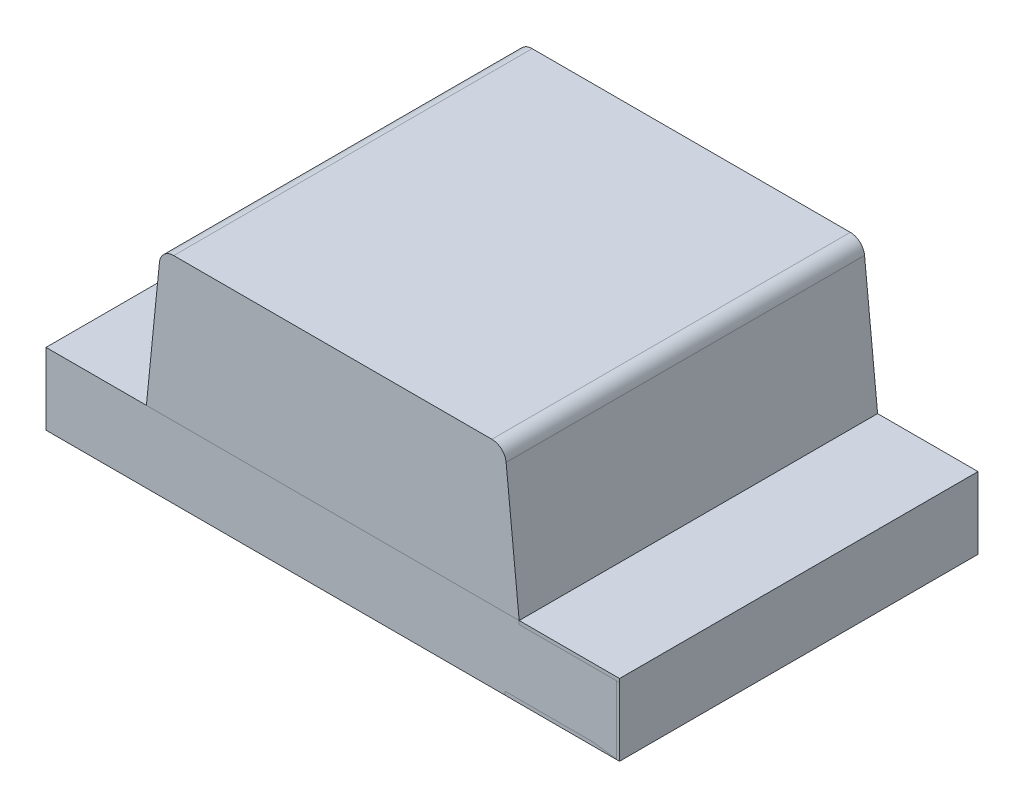
from build123d import *

# Parameters (mm, degrees)
SKETCH1_W             = 2
SKETCH1_H             = 0.25
EXTRUDE1_DEPTH        = 0.625
EXTRUDE2_DEPTH        = 0.625
EXTRUDE3_DEPTH        = 0.0001
EXTRUDE3_DEPTH_BACK   = 0.013
SKETCH2_3_W           = 0.4
SKETCH2_3_H           = 1.25
EXTRUDE4_DEPTH        = 0.0001
EXTRUDE4_DEPTH_BACK   = 0.012
EXTRUDE4_2_DEPTH      = 0.0001
EXTRUDE4_2_DEPTH_BACK = 0.012
SKETCH3_W             = 0.35
SKETCH3_H             = 1.25
EXTRUDE5_DEPTH        = 0.0001
EXTRUDE5_DEPTH_BACK   = 0.012
EXTRUDE5_2_DEPTH      = 0.0001
EXTRUDE5_2_DEPTH_BACK = 0.012
FILLET1_R             = 0.05
SKETCH5_W             = 1.25
SKETCH5_H             = 0.25
EXTRUDE6_DEPTH        = 0.0001
EXTRUDE6_DEPTH_BACK   = 0.01
SKETCH6_W             = 1.25
SKETCH6_H             = 0.2501
EXTRUDE7_DEPTH        = 0.0001
EXTRUDE7_DEPTH_BACK   = 0.01
SKETCH7_W             = 0.013291139
SKETCH7_H             = 0.012658228
CUT_EXTRUDE1_DEPTH    = 0.01


with BuildPart() as part:
    # Sketch1 → Extrude1 (new body, symmetric)
    with BuildSketch(Plane.XY):
        Rectangle(SKETCH1_W, SKETCH1_H)
    extrude(amount=EXTRUDE1_DEPTH, both=True)


with BuildPart() as body_2:
    # Sketch1_3 → Extrude2 (new body, symmetric)
    with BuildSketch(Plane.XY):
        Polygon((-0.6, 0.625), (-0.65, 0.125), (0.65, 0.125), (0.6, 0.625), align=None)
    extrude(amount=EXTRUDE2_DEPTH, both=True)

    # Fillet1
    fillet1_edges = [body_2.edges().sort_by_distance(p)[0] for p in [
        (0.6, 0.625, 0),
        (-0.6, 0.625, 0),
    ]]
    fillet(fillet1_edges, radius=FILLET1_R)


with BuildPart() as body_3:
    # Sketch2 → Extrude3 (new body, two sides)
    with BuildSketch(Plane.XZ.offset(0.125)) as extrude3_sk:
        Polygon((-0.339833711, 0.625), (-0.339833711, -0.625), (0.32532124, 0), align=None)
    extrude(amount=EXTRUDE3_DEPTH)
    extrude(extrude3_sk.sketch, amount=-EXTRUDE3_DEPTH_BACK)


with BuildPart() as body_4:
    # Sketch2_3 → Extrude4 (new body, two sides)
    with BuildSketch(Plane.XZ.offset(0.125)) as extrude4_sk:
        with Locations((-0.8, 0)):
            Rectangle(SKETCH2_3_W, SKETCH2_3_H)
    extrude(amount=EXTRUDE4_DEPTH)
    extrude(extrude4_sk.sketch, amount=-EXTRUDE4_DEPTH_BACK)


with BuildPart() as body_5:
    # Sketch2_3 → Extrude4 2 (new body, two sides)
    with BuildSketch(Plane.XZ.offset(0.125)) as extrude4_2_sk:
        with Locations((0.8, 0)):
            Rectangle(SKETCH2_3_W, SKETCH2_3_H)
    extrude(amount=EXTRUDE4_2_DEPTH)
    extrude(extrude4_2_sk.sketch, amount=-EXTRUDE4_2_DEPTH_BACK)


with BuildPart() as body_6:
    # Sketch3 → Extrude5 (new body, two sides)
    with BuildSketch(Plane(origin=(0, 0.125, 0), x_dir=(-1, 0, 0), z_dir=(0, 1, 0))) as extrude5_sk:
        with Locations((0.825, 0)):
            Rectangle(SKETCH3_W, SKETCH3_H)
    extrude(amount=EXTRUDE5_DEPTH)
    extrude(extrude5_sk.sketch, amount=-EXTRUDE5_DEPTH_BACK)


with BuildPart() as body_7:
    # Sketch3 → Extrude5 2 (new body, two sides)
    with BuildSketch(Plane(origin=(0, 0.125, 0), x_dir=(-1, 0, 0), z_dir=(0, 1, 0))) as extrude5_2_sk:
        with Locations((-0.825, 0)):
            Rectangle(SKETCH3_W, SKETCH3_H)
    extrude(amount=EXTRUDE5_2_DEPTH)
    extrude(extrude5_2_sk.sketch, amount=-EXTRUDE5_2_DEPTH_BACK)


with BuildPart() as body_8:
    # Sketch5 → Extrude6 (new body, two sides)
    with BuildSketch(Plane(origin=(1, 0, 0), x_dir=(0, 0, -1), z_dir=(1, 0, 0))) as extrude6_sk:
        Rectangle(SKETCH5_W, SKETCH5_H)
    extrude(amount=EXTRUDE6_DEPTH)
    extrude(extrude6_sk.sketch, amount=-EXTRUDE6_DEPTH_BACK)


with BuildPart() as body_9:
    # Sketch6 → Extrude7 (new body, two sides)
    with BuildSketch(Plane.ZY.offset(1)) as extrude7_sk:
        with Locations((0, -5e-05)):
            Rectangle(SKETCH6_W, SKETCH6_H)
    extrude(amount=EXTRUDE7_DEPTH)
    extrude(extrude7_sk.sketch, amount=-EXTRUDE7_DEPTH_BACK)


with BuildPart() as cut_extrude1_tool:
    # Sketch7 → Cut-Extrude1 (new body)
    with BuildSketch(Plane.XZ.offset(0.1251)):
        Polygon((-0.87901904, 0.291273719), (-0.916360812, 0.303002358), (-0.916360812, 0.315373798), (-0.891192695, 0.323581868), (-0.916360812, 0.331344922), (-0.916360812, 0.344210823), (-0.87901904, 0.355830681), (-0.87901904, 0.343241678), (-0.904760733, 0.336744447), (-0.87901904, 0.328536377), (-0.87901904, 0.317786773), (-0.904760733, 0.309628149), (-0.87901904, 0.303219922), align=None)
        Polygon((-0.87901904, 0.224185111), (-0.916360812, 0.235913751), (-0.916360812, 0.248285191), (-0.891192695, 0.25649326), (-0.916360812, 0.264256314), (-0.916360812, 0.277122216), (-0.87901904, 0.288742073), (-0.87901904, 0.27615307), (-0.904760733, 0.269655839), (-0.87901904, 0.26144777), (-0.87901904, 0.250698165), (-0.904760733, 0.242539542), (-0.87901904, 0.236131314), align=None)
        Polygon((-0.87901904, 0.157096504), (-0.916360812, 0.168825143), (-0.916360812, 0.181196583), (-0.891192695, 0.189404653), (-0.916360812, 0.197167706), (-0.916360812, 0.210033608), (-0.87901904, 0.221653466), (-0.87901904, 0.209064463), (-0.904760733, 0.202567232), (-0.87901904, 0.194359162), (-0.87901904, 0.183609558), (-0.904760733, 0.175450934), (-0.87901904, 0.169042706), align=None)
        with Locations((-0.909715243, 0.143172453)):
            Rectangle(SKETCH7_W, SKETCH7_H)
        with BuildLine():
            add(Edge.make_bspline(
                [(-0.900775369, 0.084944605), (-0.901386436, 0.084962854), (-0.902586367, 0.084998689), (-0.904340211, 0.085303483), (-0.906002363, 0.085800466), (-0.907584436, 0.086486636), (-0.90906918, 0.087383364), (-0.910470626, 0.088474999), (-0.911772898, 0.089769441), (-0.912991086, 0.091242843), (-0.914082141, 0.092891314), (-0.915035158, 0.094690171), (-0.915832493, 0.096630185), (-0.916502026, 0.09870429), (-0.916996243, 0.100927564), (-0.917358237, 0.103286313), (-0.917594895, 0.105783027), (-0.917615879, 0.107494815), (-0.917626635, 0.108372216)],
                knots=[0, 0, 0, 0, 0.907312236, 1.78165839, 2.635367075, 3.479697475, 4.336364812, 5.205276731, 6.11257575, 7.058770404, 8.040786331, 9.044147278, 10.078219212, 11.153049307, 12.278104542, 13.457648573, 14.696882856, 16, 16, 16, 16], degree=3))
            add(Edge.make_bspline(
                [(-0.917626635, 0.108372216), (-0.917614599, 0.109381344), (-0.917591287, 0.111335935), (-0.917376987, 0.114167697), (-0.917053918, 0.116801716), (-0.916570647, 0.119249573), (-0.915970264, 0.121551873), (-0.915324618, 0.123768507), (-0.914592411, 0.125909163), (-0.914042332, 0.127295707), (-0.913769831, 0.12798258)],
                knots=[0, 0, 0, 0, 1.203215828, 2.33052265, 3.384689099, 4.366106119, 5.303329643, 6.221311756, 7.118865988, 8, 8, 8, 8], degree=3))
            Line((-0.913769831, 0.12798258), (-0.90180385, 0.12798258))
            Line((-0.90180385, 0.12798258), (-0.90180385, 0.126558529))
            add(Edge.make_bspline(
                [(-0.90180385, 0.126558529), (-0.902344578, 0.125875872), (-0.903422858, 0.124514566), (-0.904804161, 0.122297949), (-0.906005242, 0.119974126), (-0.906992243, 0.117551391), (-0.907785405, 0.115102969), (-0.908332169, 0.11266528), (-0.908705843, 0.110282486), (-0.908746097, 0.108703201), (-0.908765876, 0.1079272)],
                knots=[0, 0, 0, 0, 1.030622468, 2.055194264, 3.087043286, 4.125157485, 5.149848264, 6.130935704, 7.081611712, 8, 8, 8, 8], degree=3))
            add(Edge.make_bspline(
                [(-0.908765876, 0.1079272), (-0.908765428, 0.107712811), (-0.908764471, 0.10725382), (-0.908700049, 0.106519801), (-0.908653468, 0.105690502), (-0.908548859, 0.104801069), (-0.908439567, 0.10390566), (-0.908249407, 0.10307833), (-0.908068488, 0.10232651), (-0.907884399, 0.101873269), (-0.90779673, 0.101657422)],
                knots=[0, 0, 0, 0, 0.806378557, 1.726393851, 2.771014456, 3.931269413, 5.096090628, 6.161710732, 7.124547685, 8, 8, 8, 8], degree=3))
            add(Edge.make_bspline(
                [(-0.90779673, 0.101657422), (-0.907682818, 0.101417528), (-0.907458957, 0.100946087), (-0.907050154, 0.100298627), (-0.906614503, 0.099707291), (-0.906131793, 0.09917656), (-0.905542839, 0.098751427), (-0.904842411, 0.098437326), (-0.904017261, 0.098265779), (-0.903429755, 0.098246132), (-0.903119119, 0.098235744)],
                knots=[0, 0, 0, 0, 1.024407818, 2.013179384, 2.949802342, 3.859052226, 4.77034807, 5.732977883, 6.801339628, 8, 8, 8, 8], degree=3))
            add(Edge.make_bspline(
                [(-0.903119119, 0.098235744), (-0.902846171, 0.098251465), (-0.902309475, 0.098282377), (-0.901545477, 0.098573273), (-0.900834538, 0.099014722), (-0.900204181, 0.099658233), (-0.899625462, 0.100455271), (-0.899140313, 0.10143314), (-0.898700276, 0.102559629), (-0.898491642, 0.103381859), (-0.898382173, 0.103813276)],
                knots=[0, 0, 0, 0, 0.825212765, 1.622611382, 2.449701629, 3.348069183, 4.336544339, 5.428209675, 6.6506027, 8, 8, 8, 8], degree=3))
            add(Edge.make_bspline(
                [(-0.898382173, 0.103813276), (-0.898158303, 0.10479764), (-0.897699708, 0.106814093), (-0.897126154, 0.109888148), (-0.896493118, 0.112953262), (-0.895888347, 0.114932618), (-0.895593407, 0.115897928)],
                knots=[0, 0, 0, 0, 0.976104583, 1.999535498, 3.024395274, 4, 4, 4, 4], degree=3))
            add(Edge.make_bspline(
                [(-0.895593407, 0.115897928), (-0.895416911, 0.116417186), (-0.895073344, 0.11742797), (-0.894492532, 0.118873742), (-0.893857556, 0.120204298), (-0.89317999, 0.121424353), (-0.892442991, 0.122524014), (-0.891676296, 0.123521609), (-0.890849378, 0.124393372), (-0.889983418, 0.125167214), (-0.889057417, 0.125828871), (-0.888085348, 0.126406247), (-0.887055116, 0.126894064), (-0.885974471, 0.127298506), (-0.884835037, 0.127607042), (-0.8836466, 0.12781767), (-0.88240492, 0.127966865), (-0.881557744, 0.12797727), (-0.881125448, 0.12798258)],
                knots=[0, 0, 0, 0, 1.287286806, 2.505824366, 3.654938963, 4.74627059, 5.778586806, 6.75996495, 7.696030012, 8.595059759, 9.482019644, 10.363222407, 11.245851011, 12.154256429, 13.068444161, 14.012503255, 14.985824751, 16, 16, 16, 16], degree=3))
            add(Edge.make_bspline(
                [(-0.881125448, 0.12798258), (-0.880547376, 0.127963929), (-0.87940974, 0.127927224), (-0.877745218, 0.12762651), (-0.876170849, 0.127113215), (-0.874669118, 0.126420183), (-0.873262575, 0.125505869), (-0.871923301, 0.124413472), (-0.870687505, 0.123101448), (-0.869537339, 0.121612887), (-0.868497639, 0.119969195), (-0.867582361, 0.118199703), (-0.866814035, 0.116315059), (-0.866177088, 0.114322285), (-0.865699753, 0.112213051), (-0.865340287, 0.109994435), (-0.865133696, 0.10765754), (-0.865108071, 0.106061829), (-0.865094989, 0.105247216)],
                knots=[0, 0, 0, 0, 0.894990994, 1.761326291, 2.609044902, 3.454222546, 4.315366365, 5.200560057, 6.125081389, 7.100429509, 8.110379559, 9.133447974, 10.182136699, 11.259192205, 12.370181258, 13.528580438, 14.738335141, 16, 16, 16, 16], degree=3))
            add(Edge.make_bspline(
                [(-0.865094989, 0.105247216), (-0.865106085, 0.104412872), (-0.865128258, 0.1027456), (-0.865317247, 0.100254879), (-0.865594861, 0.097774628), (-0.866015714, 0.095342713), (-0.866503922, 0.092997435), (-0.86705182, 0.090790817), (-0.867670802, 0.088751087), (-0.868147975, 0.087464255), (-0.868378217, 0.086843339)],
                knots=[0, 0, 0, 0, 1.065403572, 2.129000689, 3.188532477, 4.251604565, 5.279552602, 6.247508681, 7.154397237, 8, 8, 8, 8], degree=3))
            Line((-0.868378217, 0.086843339), (-0.879651951, 0.086843339))
            Line((-0.879651951, 0.086843339), (-0.879651951, 0.088257501))
            add(Edge.make_bspline(
                [(-0.879651951, 0.088257501), (-0.879251778, 0.088793953), (-0.878433413, 0.089891012), (-0.877391577, 0.091720831), (-0.876412644, 0.093699948), (-0.875570565, 0.095839364), (-0.874840824, 0.098068877), (-0.874331241, 0.100360357), (-0.874010336, 0.102673439), (-0.873973949, 0.104224294), (-0.873955749, 0.104999985)],
                knots=[0, 0, 0, 0, 0.892283326, 1.824742884, 2.804416662, 3.836872171, 4.8899239, 5.931447339, 6.965372909, 8, 8, 8, 8], degree=3))
            add(Edge.make_bspline(
                [(-0.873955749, 0.104999985), (-0.873966475, 0.105547819), (-0.873987926, 0.106643427), (-0.874183268, 0.108277531), (-0.874498715, 0.109898562), (-0.874908356, 0.110918823), (-0.87511279, 0.111427991)],
                knots=[0, 0, 0, 0, 0.999146175, 1.998183711, 3.000980573, 4, 4, 4, 4], degree=3))
            add(Edge.make_bspline(
                [(-0.87511279, 0.111427991), (-0.875213524, 0.111644743), (-0.875414923, 0.112078101), (-0.875801205, 0.112681424), (-0.876265611, 0.113233758), (-0.876791607, 0.113729797), (-0.877369793, 0.114163996), (-0.878007206, 0.114471671), (-0.878688664, 0.114659608), (-0.879156279, 0.114680687), (-0.879394831, 0.114691441)],
                knots=[0, 0, 0, 0, 1.00524851, 2.009826503, 3.004679593, 4.035271301, 5.048246368, 6.034938417, 6.997532266, 8, 8, 8, 8], degree=3))
            add(Edge.make_bspline(
                [(-0.879394831, 0.114691441), (-0.879713914, 0.114674221), (-0.880323652, 0.114641317), (-0.88118155, 0.114338025), (-0.881920767, 0.113845608), (-0.882418227, 0.113265306), (-0.882766946, 0.112706741), (-0.883022201, 0.112188912), (-0.88326388, 0.111584298), (-0.883512615, 0.110898674), (-0.883758208, 0.110130511), (-0.883995982, 0.109276232), (-0.88422063, 0.108334874), (-0.884363725, 0.107676936), (-0.884438344, 0.107333846)],
                knots=[0, 0, 0, 0, 1.173816843, 2.243057204, 3.312297565, 4.415174738, 5.03266065, 5.73970059, 6.541434878, 7.433956553, 8.430083051, 9.515931566, 10.70464786, 12, 12, 12, 12], degree=3))
            add(Edge.make_bspline(
                [(-0.884438344, 0.107333846), (-0.884626375, 0.106417451), (-0.884995814, 0.104616938), (-0.885547558, 0.101916346), (-0.886185042, 0.099164959), (-0.886759444, 0.097332296), (-0.887058993, 0.096376567)],
                knots=[0, 0, 0, 0, 0.995744513, 1.956417928, 2.934277412, 4, 4, 4, 4], degree=3))
            add(Edge.make_bspline(
                [(-0.887058993, 0.096376567), (-0.887218615, 0.09590329), (-0.887530861, 0.094977484), (-0.888074002, 0.093657168), (-0.888660994, 0.092433639), (-0.889281759, 0.091300122), (-0.889953742, 0.090263138), (-0.890665066, 0.089315796), (-0.89142852, 0.088473887), (-0.892235134, 0.087725104), (-0.893090184, 0.087065525), (-0.894009721, 0.086499375), (-0.894984122, 0.086013261), (-0.896027222, 0.085628459), (-0.897124515, 0.085319449), (-0.898290199, 0.0851079), (-0.899512387, 0.084960908), (-0.900349676, 0.0849501), (-0.900775369, 0.084944605)],
                knots=[0, 0, 0, 0, 1.237467875, 2.420686895, 3.535046182, 4.599015201, 5.620884487, 6.594603852, 7.531477383, 8.433220087, 9.318759595, 10.202828513, 11.105163009, 12.01247538, 12.953896178, 13.926381251, 14.945733412, 16, 16, 16, 16], degree=3))
        make_face()
        with BuildLine():
            Line((-0.916360812, 0.038742073), (-0.916360812, 0.05076739))
            Line((-0.916360812, 0.05076739), (-0.912444673, 0.05076739))
            add(Edge.make_bspline(
                [(-0.912444673, 0.05076739), (-0.912848952, 0.051314044), (-0.913628397, 0.052367986), (-0.914668505, 0.053954498), (-0.915556138, 0.055467544), (-0.916335749, 0.056924289), (-0.916923441, 0.058435391), (-0.917337474, 0.060051148), (-0.917587361, 0.06180256), (-0.917613253, 0.063016007), (-0.917626635, 0.063643181)],
                knots=[0, 0, 0, 0, 1.150872466, 2.218865267, 3.209461834, 4.120482262, 5.012764827, 5.946708227, 6.938749913, 8, 8, 8, 8], degree=3))
            add(Edge.make_bspline(
                [(-0.917626635, 0.063643181), (-0.917615276, 0.064151357), (-0.917593155, 0.065140922), (-0.917420716, 0.066579542), (-0.917151891, 0.067933356), (-0.916748095, 0.069190876), (-0.916265194, 0.070372871), (-0.915625215, 0.071441646), (-0.914910128, 0.072443446), (-0.914056605, 0.073334283), (-0.913107738, 0.074142093), (-0.912041508, 0.074833368), (-0.910875045, 0.075422224), (-0.909599118, 0.075892773), (-0.908219967, 0.076270318), (-0.906730343, 0.076532284), (-0.905136779, 0.07669258), (-0.904039214, 0.07670855), (-0.903475132, 0.076716757)],
                knots=[0, 0, 0, 0, 1.109008058, 2.159558935, 3.158726032, 4.116861086, 5.039058877, 5.938775559, 6.82970133, 7.720510853, 8.624361809, 9.544451588, 10.487360536, 11.471068125, 12.508000841, 13.604731202, 14.768976642, 16, 16, 16, 16], degree=3))
            Line((-0.903475132, 0.076716757), (-0.87901904, 0.076716757))
            Line((-0.87901904, 0.076716757), (-0.87901904, 0.064691441))
            Line((-0.87901904, 0.064691441), (-0.897808597, 0.064691441))
            add(Edge.make_bspline(
                [(-0.897808597, 0.064691441), (-0.898266833, 0.064690623), (-0.89914394, 0.064689057), (-0.900396844, 0.064647888), (-0.90153093, 0.064587438), (-0.902551944, 0.064518085), (-0.90347532, 0.064391577), (-0.9043084, 0.064202723), (-0.905068201, 0.06396731), (-0.905521552, 0.06373515), (-0.905739768, 0.063623403)],
                knots=[0, 0, 0, 0, 1.361401701, 2.605856924, 3.723918663, 4.735739235, 5.645738665, 6.489217889, 7.27279937, 8, 8, 8, 8], degree=3))
            add(Edge.make_bspline(
                [(-0.905739768, 0.063623403), (-0.905939125, 0.063508399), (-0.906331045, 0.063282312), (-0.906834134, 0.062822168), (-0.907256268, 0.062282796), (-0.907584282, 0.061643994), (-0.907833757, 0.06090072), (-0.908003875, 0.060036755), (-0.908111626, 0.059044074), (-0.90812558, 0.058339565), (-0.908132964, 0.057966757)],
                knots=[0, 0, 0, 0, 0.849138082, 1.669332372, 2.503455908, 3.370611167, 4.311442699, 5.394692208, 6.621337967, 8, 8, 8, 8], degree=3))
            add(Edge.make_bspline(
                [(-0.908132964, 0.057966757), (-0.908124286, 0.057696115), (-0.908106442, 0.057139656), (-0.907990219, 0.056284), (-0.907811882, 0.055385711), (-0.907481954, 0.05412842), (-0.906888864, 0.052545107), (-0.906211661, 0.051365456), (-0.905868328, 0.05076739)],
                knots=[0, 0, 0, 0, 0.638127216, 1.312033637, 2.033062677, 2.79661882, 4.375931797, 6, 6, 6, 6], degree=3))
            Line((-0.905868328, 0.05076739), (-0.87901904, 0.05076739))
            Line((-0.87901904, 0.05076739), (-0.87901904, 0.038742073))
            Line((-0.87901904, 0.038742073), (-0.916360812, 0.038742073))
        make_face()
        with BuildLine():
            Line((-0.916360812, -0.009992104), (-0.916360812, 0.002033213))
            Line((-0.916360812, 0.002033213), (-0.897571255, 0.002033213))
            add(Edge.make_bspline(
                [(-0.897571255, 0.002033213), (-0.896806234, 0.00204547), (-0.895280721, 0.002069912), (-0.893399516, 0.002210974), (-0.891978354, 0.002400235), (-0.891059413, 0.002585062), (-0.890285344, 0.002800912), (-0.889842464, 0.003007052), (-0.889640084, 0.003101251)],
                knots=[0, 0, 0, 0, 1.709124929, 3.408128882, 4.211124727, 4.91016634, 5.501986363, 6, 6, 6, 6], degree=3))
            add(Edge.make_bspline(
                [(-0.889640084, 0.003101251), (-0.889441058, 0.003223482), (-0.889050838, 0.003463134), (-0.888544331, 0.003931796), (-0.888129911, 0.004478739), (-0.887789136, 0.005114124), (-0.887553845, 0.005859722), (-0.88735723, 0.006718092), (-0.887273776, 0.007711401), (-0.887256196, 0.008415036), (-0.887246888, 0.008787564)],
                knots=[0, 0, 0, 0, 0.86006424, 1.686277094, 2.52783008, 3.38194165, 4.331801563, 5.402842185, 6.624978739, 8, 8, 8, 8], degree=3))
            add(Edge.make_bspline(
                [(-0.887246888, 0.008787564), (-0.887275257, 0.009353475), (-0.887333184, 0.010509022), (-0.887688937, 0.011940119), (-0.888098417, 0.013105421), (-0.888477832, 0.014031683), (-0.888963553, 0.014985998), (-0.889324464, 0.015625704), (-0.889511524, 0.015957263)],
                knots=[0, 0, 0, 0, 1.338371478, 2.732853438, 3.468019217, 4.261884641, 5.099136535, 6, 6, 6, 6], degree=3))
            Line((-0.889511524, 0.015957263), (-0.916360812, 0.015957263))
            Line((-0.916360812, 0.015957263), (-0.916360812, 0.02798258))
            Line((-0.916360812, 0.02798258), (-0.87901904, 0.02798258))
            Line((-0.87901904, 0.02798258), (-0.87901904, 0.015957263))
            Line((-0.87901904, 0.015957263), (-0.882935179, 0.015957263))
            add(Edge.make_bspline(
                [(-0.882935179, 0.015957263), (-0.882532104, 0.01542856), (-0.881747492, 0.014399408), (-0.880727282, 0.012809789), (-0.879827898, 0.01126784), (-0.879071489, 0.009741335), (-0.878468102, 0.008183858), (-0.878062607, 0.006552478), (-0.877790706, 0.004844275), (-0.877765859, 0.003675918), (-0.877753217, 0.003081472)],
                knots=[0, 0, 0, 0, 1.126119141, 2.192057864, 3.198061997, 4.149848529, 5.076251285, 6.021887753, 6.99356175, 8, 8, 8, 8], degree=3))
            add(Edge.make_bspline(
                [(-0.877753217, 0.003081472), (-0.877765912, 0.002583336), (-0.877790694, 0.001610887), (-0.877945549, 0.000193507), (-0.878220881, -0.001142204), (-0.878619796, -0.002388341), (-0.879112601, -0.003559651), (-0.879728359, -0.004640623), (-0.88045757, -0.005636658), (-0.881288072, -0.006550859), (-0.882232935, -0.007366268), (-0.883291567, -0.008074786), (-0.884463115, -0.008664777), (-0.88574327, -0.009150133), (-0.887125824, -0.009537344), (-0.888623807, -0.00979491), (-0.890225897, -0.009971802), (-0.891333918, -0.009985201), (-0.89190472, -0.009992104)],
                knots=[0, 0, 0, 0, 1.08848837, 2.124922927, 3.110950502, 4.063144162, 4.979605775, 5.882838355, 6.774625441, 7.671951181, 8.57587277, 9.494821853, 10.448322275, 11.435533005, 12.482327682, 13.580118324, 14.753386918, 16, 16, 16, 16], degree=3))
            Line((-0.89190472, -0.009992104), (-0.916360812, -0.009992104))
        make_face()
        Polygon((-0.916360812, -0.057460458), (-0.916360812, -0.021384509), (-0.866360812, -0.021384509), (-0.866360812, -0.034042737), (-0.906867141, -0.034042737), (-0.906867141, -0.057460458), align=None)
        Polygon((-0.916360812, -0.101131344), (-0.916360812, -0.065055395), (-0.866360812, -0.065055395), (-0.866360812, -0.101131344), (-0.875854483, -0.101131344), (-0.875854483, -0.077713623), (-0.884715243, -0.077713623), (-0.884715243, -0.09923261), (-0.894208914, -0.09923261), (-0.894208914, -0.077713623), (-0.906867141, -0.077713623), (-0.906867141, -0.101131344), align=None)
        with BuildLine():
            add(Edge.make_bspline(
                [(-0.891410258, -0.159359192), (-0.891984103, -0.159349535), (-0.893120546, -0.159330409), (-0.894802949, -0.159182813), (-0.896435787, -0.1589198), (-0.898027911, -0.15858021), (-0.899567375, -0.158118957), (-0.901071164, -0.1575781), (-0.90252391, -0.156923277), (-0.903924628, -0.156170851), (-0.905260679, -0.155346115), (-0.906520783, -0.15445874), (-0.907712392, -0.15353585), (-0.908809839, -0.152541194), (-0.909830849, -0.151501603), (-0.910776256, -0.150413839), (-0.911627972, -0.149261307), (-0.912139414, -0.148457726), (-0.912395227, -0.148055791)],
                knots=[0, 0, 0, 0, 1.105570398, 2.18947457, 3.250358341, 4.290584537, 5.323553275, 6.344225964, 7.367641686, 8.3905646, 9.405808457, 10.390761353, 11.358902336, 12.307789878, 13.241960776, 14.165076779, 15.082208636, 16, 16, 16, 16], degree=3))
            add(Edge.make_bspline(
                [(-0.912395227, -0.148055791), (-0.912751296, -0.147436176), (-0.913465253, -0.146193787), (-0.914299548, -0.144201869), (-0.915001606, -0.142139128), (-0.915528818, -0.139963935), (-0.91589234, -0.13764043), (-0.916172743, -0.135139725), (-0.916323623, -0.132435931), (-0.916348133, -0.130568483), (-0.916360812, -0.129602468)],
                knots=[0, 0, 0, 0, 0.896288622, 1.797150563, 2.705281913, 3.629615989, 4.602417572, 5.655716007, 6.787320449, 8, 8, 8, 8], degree=3))
            Line((-0.916360812, -0.129602468), (-0.916360812, -0.111890838))
            Line((-0.916360812, -0.111890838), (-0.866360812, -0.111890838))
            Line((-0.866360812, -0.111890838), (-0.866360812, -0.130106819))
            add(Edge.make_bspline(
                [(-0.866360812, -0.130106819), (-0.866369118, -0.131096185), (-0.866385138, -0.133004549), (-0.866593933, -0.135762969), (-0.866892345, -0.138315573), (-0.867354781, -0.140658247), (-0.867912453, -0.142808249), (-0.868592018, -0.144770987), (-0.869341371, -0.146576874), (-0.869978218, -0.147666295), (-0.870286841, -0.14819424)],
                knots=[0, 0, 0, 0, 1.267175336, 2.444223962, 3.542125549, 4.557526608, 5.500936977, 6.385043188, 7.217374394, 8, 8, 8, 8], degree=3))
            add(Edge.make_bspline(
                [(-0.870286841, -0.14819424), (-0.870555111, -0.148619717), (-0.871088568, -0.149465779), (-0.871979494, -0.150666386), (-0.872957532, -0.1517811), (-0.873983442, -0.152845351), (-0.875084885, -0.15383526), (-0.876254239, -0.15475686), (-0.877493286, -0.155608768), (-0.87879802, -0.15638775), (-0.880163046, -0.157098158), (-0.881599576, -0.157692811), (-0.883088841, -0.158217485), (-0.884643322, -0.158620253), (-0.88624724, -0.15896921), (-0.887917912, -0.159186578), (-0.889644156, -0.159329883), (-0.890816601, -0.15934934), (-0.891410258, -0.159359192)],
                knots=[0, 0, 0, 0, 0.964065863, 1.917049184, 2.86229036, 3.805247319, 4.749389377, 5.698846072, 6.657678277, 7.629829384, 8.610569287, 9.604676042, 10.607940105, 11.6349849, 12.681042988, 13.752616828, 14.862056989, 16, 16, 16, 16], degree=3))
        make_face()
        with BuildLine():
            add(Edge.make_bspline(
                [(-0.891331145, -0.146068053), (-0.890928765, -0.146062933), (-0.890139473, -0.146052889), (-0.888981715, -0.145957105), (-0.88786689, -0.145827577), (-0.886799544, -0.14561205), (-0.885769759, -0.145362227), (-0.884791012, -0.145041152), (-0.883851225, -0.144678954), (-0.882962481, -0.144238135), (-0.88210829, -0.143751316), (-0.881315532, -0.14317757), (-0.880559089, -0.142553401), (-0.879845097, -0.141864257), (-0.879192149, -0.141092787), (-0.878577111, -0.140262736), (-0.878012948, -0.139362557), (-0.877682923, -0.138726063), (-0.877515876, -0.138403892)],
                knots=[0, 0, 0, 0, 1.152093354, 2.259898929, 3.325467225, 4.364140538, 5.376172865, 6.358396836, 7.312077728, 8.257828931, 9.196960457, 10.124297759, 11.056236784, 12.004246951, 12.961658638, 13.947279359, 14.960983522, 16, 16, 16, 16], degree=3))
            add(Edge.make_bspline(
                [(-0.877515876, -0.138403892), (-0.87736252, -0.138066443), (-0.877058557, -0.137397596), (-0.876692961, -0.136362184), (-0.876406543, -0.135317493), (-0.876191114, -0.134216693), (-0.876030149, -0.132981813), (-0.87593152, -0.131519022), (-0.875860435, -0.129791067), (-0.875856559, -0.12854771), (-0.875854483, -0.12788174)],
                knots=[0, 0, 0, 0, 0.826967603, 1.639107464, 2.447640171, 3.242670507, 4.14065217, 5.225198036, 6.513753944, 8, 8, 8, 8], degree=3))
            Line((-0.875854483, -0.12788174), (-0.875854483, -0.124549066))
            Line((-0.875854483, -0.124549066), (-0.906867141, -0.124549066))
            Line((-0.906867141, -0.124549066), (-0.906867141, -0.12788174))
            add(Edge.make_bspline(
                [(-0.906867141, -0.12788174), (-0.906864767, -0.128260843), (-0.906860182, -0.128992726), (-0.906838651, -0.130050848), (-0.906815207, -0.131033746), (-0.906756976, -0.131936181), (-0.906720653, -0.132765524), (-0.906631463, -0.133508914), (-0.906560373, -0.134180159), (-0.906426512, -0.134963957), (-0.90621842, -0.13589054), (-0.905879331, -0.13697117), (-0.905454133, -0.138041438), (-0.90511165, -0.138735724), (-0.904938739, -0.139086249)],
                knots=[0, 0, 0, 0, 1.186793418, 2.291178421, 3.313283093, 4.264083014, 5.122158624, 5.910777728, 6.607099052, 7.234812932, 8.398911528, 9.577194775, 10.776795607, 12, 12, 12, 12], degree=3))
            add(Edge.make_bspline(
                [(-0.904938739, -0.139086249), (-0.904767981, -0.139378807), (-0.904431224, -0.13995577), (-0.903864187, -0.140767523), (-0.903260325, -0.141521381), (-0.902616099, -0.142219387), (-0.901921979, -0.142851037), (-0.901188708, -0.143427047), (-0.900414719, -0.143942271), (-0.89931796, -0.144559966), (-0.897802491, -0.145171589), (-0.895818798, -0.14569136), (-0.893638917, -0.146009796), (-0.892120108, -0.146048136), (-0.891331145, -0.146068053)],
                knots=[0, 0, 0, 0, 0.755160452, 1.489275589, 2.205657296, 2.907868421, 3.605098304, 4.296256403, 4.985378686, 5.676536785, 7.100390329, 8.614249252, 10.241231541, 12, 12, 12, 12], degree=3))
        make_face(mode=Mode.SUBTRACT)
        with Locations((-0.909715243, -0.175181977)):
            Rectangle(SKETCH7_W, SKETCH7_H)
        with BuildLine():
            add(Edge.make_bspline(
                [(-0.917626635, -0.212503971), (-0.917615729, -0.211708914), (-0.917594324, -0.210148346), (-0.917355865, -0.207862675), (-0.916997017, -0.205680089), (-0.916486564, -0.203606935), (-0.915812816, -0.201650039), (-0.914986348, -0.199818221), (-0.913993756, -0.198114792), (-0.913204152, -0.197085469), (-0.912810575, -0.196572404)],
                knots=[0, 0, 0, 0, 1.123670284, 2.205584497, 3.245308791, 4.249063313, 5.220352711, 6.167273909, 7.086481357, 8, 8, 8, 8], degree=3))
            add(Edge.make_bspline(
                [(-0.912810575, -0.196572404), (-0.912383188, -0.196096531), (-0.911530066, -0.195146623), (-0.910044353, -0.193913657), (-0.908402831, -0.192852114), (-0.90660172, -0.191959338), (-0.904643355, -0.191243876), (-0.902521024, -0.190732309), (-0.900240634, -0.190422686), (-0.898666667, -0.190389104), (-0.897858043, -0.190371851)],
                knots=[0, 0, 0, 0, 0.916457077, 1.82937027, 2.759194969, 3.714948755, 4.706655623, 5.743329475, 6.840637961, 8, 8, 8, 8], degree=3))
            add(Edge.make_bspline(
                [(-0.897858043, -0.190371851), (-0.89700643, -0.190391231), (-0.89535589, -0.190428792), (-0.892969796, -0.190760672), (-0.890760956, -0.191295478), (-0.888735001, -0.192064257), (-0.886888406, -0.193029478), (-0.885202488, -0.194161725), (-0.883681026, -0.195471988), (-0.882808306, -0.196475557), (-0.882371493, -0.196977863)],
                knots=[0, 0, 0, 0, 1.171797512, 2.271099083, 3.308930235, 4.294129479, 5.24602549, 6.17106565, 7.084581485, 8, 8, 8, 8], degree=3))
            add(Edge.make_bspline(
                [(-0.882371493, -0.196977863), (-0.881987199, -0.197490798), (-0.881213971, -0.198522864), (-0.880263622, -0.200224617), (-0.879466229, -0.202036224), (-0.878842406, -0.20395101), (-0.878365454, -0.205937414), (-0.878003532, -0.207967244), (-0.877793253, -0.21004037), (-0.877766627, -0.21143547), (-0.877753217, -0.212138069)],
                knots=[0, 0, 0, 0, 0.952130878, 1.915761808, 2.890227217, 3.891541892, 4.905612075, 5.925811839, 6.955400088, 8, 8, 8, 8], degree=3))
            add(Edge.make_bspline(
                [(-0.877753217, -0.212138069), (-0.877761718, -0.212761428), (-0.877778435, -0.213987164), (-0.877939489, -0.215787687), (-0.878206049, -0.217514958), (-0.87857535, -0.219167424), (-0.879021152, -0.220754397), (-0.879540722, -0.222279486), (-0.880107356, -0.223759391), (-0.880549624, -0.224709675), (-0.880769436, -0.225181977)],
                knots=[0, 0, 0, 0, 1.107648782, 2.178012834, 3.209595929, 4.211695017, 5.185427128, 6.137685403, 7.07440854, 8, 8, 8, 8], degree=3))
            Line((-0.880769436, -0.225181977), (-0.891044357, -0.225181977))
            Line((-0.891044357, -0.225181977), (-0.891044357, -0.223510696))
            add(Edge.make_bspline(
                [(-0.891044357, -0.223510696), (-0.890835747, -0.223260924), (-0.890384889, -0.222721106), (-0.889674513, -0.221827898), (-0.888909717, -0.220753427), (-0.888463744, -0.219926659), (-0.888225923, -0.219485775)],
                knots=[0, 0, 0, 0, 0.792826818, 1.713491785, 2.780691913, 4, 4, 4, 4], degree=3))
            add(Edge.make_bspline(
                [(-0.888225923, -0.219485775), (-0.888004944, -0.219021807), (-0.887552014, -0.218070835), (-0.887135597, -0.216792832), (-0.886851734, -0.215696831), (-0.886723523, -0.214788063), (-0.886628743, -0.213821253), (-0.886618989, -0.213153632), (-0.886613977, -0.212810537)],
                knots=[0, 0, 0, 0, 1.332524827, 2.731214173, 3.480270227, 4.267952375, 5.109889624, 6, 6, 6, 6], degree=3))
            add(Edge.make_bspline(
                [(-0.886613977, -0.212810537), (-0.886623752, -0.21242776), (-0.886642695, -0.211685954), (-0.886781223, -0.2106052), (-0.887020352, -0.209595994), (-0.887340402, -0.208644383), (-0.887784208, -0.207775352), (-0.888301027, -0.206961932), (-0.888913928, -0.206215802), (-0.889634399, -0.205556172), (-0.890424363, -0.204959808), (-0.891291421, -0.204450208), (-0.89221472, -0.20399398), (-0.893216945, -0.20364651), (-0.894281333, -0.203366641), (-0.895412893, -0.203172177), (-0.896612648, -0.203051197), (-0.897435802, -0.203037239), (-0.897858043, -0.203030078)],
                knots=[0, 0, 0, 0, 1.087302107, 2.107140881, 3.088415001, 4.030197574, 4.951552271, 5.852940509, 6.764198256, 7.685219758, 8.621679636, 9.570836121, 10.538340132, 11.542450476, 12.578202196, 13.66207107, 14.800746211, 16, 16, 16, 16], degree=3))
            add(Edge.make_bspline(
                [(-0.897858043, -0.203030078), (-0.898290121, -0.203037466), (-0.899129628, -0.203051819), (-0.900350433, -0.203168576), (-0.901491149, -0.203376521), (-0.902553809, -0.203662145), (-0.903536818, -0.204024319), (-0.904435516, -0.204476878), (-0.90526392, -0.204995056), (-0.905995226, -0.205617335), (-0.906653387, -0.206299277), (-0.907221454, -0.207056723), (-0.907695526, -0.207886342), (-0.908097758, -0.208777433), (-0.908386957, -0.209743953), (-0.908605303, -0.210772221), (-0.908749581, -0.211866999), (-0.908760363, -0.212622176), (-0.908765876, -0.213008322)],
                knots=[0, 0, 0, 0, 1.230336593, 2.390482092, 3.487897344, 4.52859895, 5.520747884, 6.465347575, 7.38981449, 8.296085817, 9.192433006, 10.084246191, 10.984321635, 11.908883871, 12.862027947, 13.850751296, 14.901019963, 16, 16, 16, 16], degree=3))
            add(Edge.make_bspline(
                [(-0.908765876, -0.213008322), (-0.908761812, -0.213371249), (-0.90875389, -0.214078762), (-0.908644851, -0.215111135), (-0.90850691, -0.21609159), (-0.908287206, -0.21700936), (-0.908016019, -0.217856993), (-0.907732765, -0.218637204), (-0.907430373, -0.219343428), (-0.907196596, -0.219774105), (-0.907084705, -0.219980237)],
                knots=[0, 0, 0, 0, 1.200823684, 2.340960236, 3.433630075, 4.476504061, 5.46014544, 6.378484521, 7.223905657, 8, 8, 8, 8], degree=3))
            add(Edge.make_bspline(
                [(-0.907084705, -0.219980237), (-0.906869757, -0.22033034), (-0.906453936, -0.221007623), (-0.905753153, -0.221926987), (-0.905046023, -0.222749421), (-0.904567915, -0.223261677), (-0.904335496, -0.223510696)],
                knots=[0, 0, 0, 0, 1.098601379, 2.125273733, 3.088655601, 4, 4, 4, 4], degree=3))
            Line((-0.904335496, -0.223510696), (-0.904335496, -0.225181977))
            Line((-0.904335496, -0.225181977), (-0.914689531, -0.225181977))
            add(Edge.make_bspline(
                [(-0.914689531, -0.225181977), (-0.914908278, -0.224709282), (-0.915345824, -0.223763779), (-0.91592276, -0.222306489), (-0.916406841, -0.220812503), (-0.916858381, -0.219288316), (-0.917202562, -0.217702275), (-0.917449123, -0.21604076), (-0.917599579, -0.21430001), (-0.917617494, -0.213110816), (-0.917626635, -0.212503971)],
                knots=[0, 0, 0, 0, 0.952012952, 1.904254716, 2.862729541, 3.822037426, 4.808956931, 5.82647221, 6.890850784, 8, 8, 8, 8], degree=3))
        make_face()
        with BuildLine():
            add(Edge.make_bspline(
                [(-0.897709705, -0.271384509), (-0.898462158, -0.271372161), (-0.899928891, -0.271348092), (-0.902064786, -0.271078434), (-0.904082785, -0.270672044), (-0.905976389, -0.270085778), (-0.907755027, -0.269345582), (-0.909399923, -0.268420112), (-0.910926538, -0.26733461), (-0.91232148, -0.266089092), (-0.913570735, -0.26468849), (-0.914668362, -0.263151399), (-0.915575083, -0.261464486), (-0.916331128, -0.25965733), (-0.916915745, -0.257715004), (-0.917322104, -0.255637895), (-0.917589839, -0.253429328), (-0.917614165, -0.251910118), (-0.917626635, -0.251131344)],
                knots=[0, 0, 0, 0, 1.120167703, 2.183507516, 3.201345984, 4.182878364, 5.131270247, 6.065524964, 6.98789854, 7.91635504, 8.84481154, 9.778033504, 10.722808862, 11.691211189, 12.691525459, 13.738229926, 14.840575679, 16, 16, 16, 16], degree=3))
            add(Edge.make_bspline(
                [(-0.917626635, -0.251131344), (-0.917614124, -0.250352584), (-0.917589718, -0.248833401), (-0.917322552, -0.246624646), (-0.916913577, -0.244545099), (-0.916335526, -0.242600445), (-0.915572252, -0.240796072), (-0.914668728, -0.239111139), (-0.913570631, -0.237574256), (-0.912321535, -0.236173513), (-0.910926422, -0.234928354), (-0.909400331, -0.233841559), (-0.907752354, -0.232920352), (-0.905980831, -0.232161425), (-0.904080412, -0.231594763), (-0.902065191, -0.231183031), (-0.899928781, -0.230914927), (-0.898462121, -0.23089064), (-0.897709705, -0.23087818)],
                knots=[0, 0, 0, 0, 1.15937715, 2.261678054, 3.308339936, 4.313313916, 5.277148057, 6.221884977, 7.155068972, 8.083487698, 9.011906424, 9.934242473, 10.868459181, 11.818729666, 12.798784262, 13.81658132, 14.879877871, 16, 16, 16, 16], degree=3))
            add(Edge.make_bspline(
                [(-0.897709705, -0.23087818), (-0.896953993, -0.230890741), (-0.895477488, -0.230915284), (-0.893328051, -0.231182969), (-0.891297726, -0.231591977), (-0.889393569, -0.232171993), (-0.887617769, -0.23293013), (-0.885966717, -0.233850642), (-0.88444343, -0.234948876), (-0.883048554, -0.236203626), (-0.881800363, -0.237609522), (-0.880713911, -0.239156488), (-0.879795582, -0.240832448), (-0.879034665, -0.242636048), (-0.878467383, -0.244579325), (-0.878058593, -0.246647797), (-0.877789557, -0.248846493), (-0.877765551, -0.250355863), (-0.877753217, -0.251131344)],
                knots=[0, 0, 0, 0, 1.124034801, 2.196132384, 3.217834281, 4.203147447, 5.152578239, 6.085969439, 7.010345409, 7.941219594, 8.872481455, 9.802010446, 10.748267785, 11.711250247, 12.709230373, 13.754967386, 14.846549946, 16, 16, 16, 16], degree=3))
            add(Edge.make_bspline(
                [(-0.877753217, -0.251131344), (-0.877765578, -0.251916713), (-0.877789645, -0.253445795), (-0.878057746, -0.255667501), (-0.878464249, -0.257754421), (-0.879047447, -0.259703733), (-0.879803153, -0.261516609), (-0.880720482, -0.263196646), (-0.881821511, -0.2647323), (-0.883075089, -0.266125927), (-0.88447779, -0.267366047), (-0.886002602, -0.268450506), (-0.88766246, -0.269354114), (-0.889439894, -0.270095), (-0.891336779, -0.270681086), (-0.893353831, -0.271091578), (-0.89549133, -0.271344574), (-0.896957395, -0.271370966), (-0.897709705, -0.271384509)],
                knots=[0, 0, 0, 0, 1.167358552, 2.272800965, 3.322628764, 4.326027541, 5.29287265, 6.238482395, 7.166210353, 8.096447471, 9.020151799, 9.945039072, 10.873038967, 11.824425184, 12.804379233, 13.820580988, 14.881633558, 16, 16, 16, 16], degree=3))
        make_face()
        with BuildLine():
            add(Edge.make_bspline(
                [(-0.906956145, -0.25653087), (-0.906706141, -0.256708458), (-0.906197355, -0.257069873), (-0.905347144, -0.257504999), (-0.904436246, -0.257899002), (-0.903421606, -0.258208099), (-0.902270383, -0.25844776), (-0.900943587, -0.258603456), (-0.89942583, -0.258718277), (-0.898349474, -0.258723508), (-0.897778929, -0.258726281)],
                knots=[0, 0, 0, 0, 0.764956307, 1.556776596, 2.379454426, 3.241401993, 4.200532455, 5.312591107, 6.575484591, 8, 8, 8, 8], degree=3))
            add(Edge.make_bspline(
                [(-0.897778929, -0.258726281), (-0.897241489, -0.258717437), (-0.89621181, -0.258700491), (-0.894731929, -0.258607307), (-0.893390216, -0.258432969), (-0.892181518, -0.25818403), (-0.891096174, -0.257879145), (-0.890124992, -0.257516177), (-0.889265691, -0.257096919), (-0.888763076, -0.256754185), (-0.8885226, -0.256590205)],
                knots=[0, 0, 0, 0, 1.337076348, 2.561692668, 3.686680134, 4.69989255, 5.629188848, 6.488203485, 7.276684665, 8, 8, 8, 8], degree=3))
            add(Edge.make_bspline(
                [(-0.8885226, -0.256590205), (-0.888302959, -0.256421556), (-0.887872081, -0.256090712), (-0.887330988, -0.255502686), (-0.886881841, -0.254870406), (-0.886551821, -0.254180256), (-0.886292192, -0.253457672), (-0.886118774, -0.252703509), (-0.886004713, -0.251925933), (-0.885989024, -0.251398765), (-0.885981065, -0.251131344)],
                knots=[0, 0, 0, 0, 1.058684453, 2.076859345, 3.046867319, 4.017860406, 4.996047344, 5.981941452, 6.976284511, 8, 8, 8, 8], degree=3))
            add(Edge.make_bspline(
                [(-0.885981065, -0.251131344), (-0.885986539, -0.250867378), (-0.885997244, -0.25035107), (-0.886087085, -0.249599737), (-0.88623438, -0.248894263), (-0.886443346, -0.248224326), (-0.886741088, -0.247578339), (-0.8871693, -0.246961167), (-0.887706965, -0.246353198), (-0.888132225, -0.245984074), (-0.888354483, -0.245791154)],
                knots=[0, 0, 0, 0, 1.041978199, 2.038073998, 2.982578265, 3.884042198, 4.804014415, 5.778706634, 6.839057036, 8, 8, 8, 8], degree=3))
            add(Edge.make_bspline(
                [(-0.888354483, -0.245791154), (-0.888591796, -0.245624412), (-0.889091096, -0.24527359), (-0.889943357, -0.244832102), (-0.890924317, -0.244466426), (-0.892016187, -0.244120306), (-0.893251761, -0.243861173), (-0.8946284, -0.243660804), (-0.896155614, -0.243560447), (-0.897221722, -0.243544659), (-0.897778929, -0.243536408)],
                knots=[0, 0, 0, 0, 0.706185926, 1.485796665, 2.33004681, 3.254820698, 4.274138656, 5.402098861, 6.642194297, 8, 8, 8, 8], degree=3))
            add(Edge.make_bspline(
                [(-0.897778929, -0.243536408), (-0.898280161, -0.243540981), (-0.899250717, -0.243549836), (-0.90065391, -0.243649293), (-0.901955876, -0.243813631), (-0.903150892, -0.244051953), (-0.904243341, -0.244339075), (-0.90521917, -0.244712812), (-0.906096699, -0.245124549), (-0.90661057, -0.245474718), (-0.906857252, -0.245642816)],
                knots=[0, 0, 0, 0, 1.270915159, 2.460926195, 3.565223763, 4.596447547, 5.549594966, 6.425286377, 7.244063354, 8, 8, 8, 8], degree=3))
            add(Edge.make_bspline(
                [(-0.906857252, -0.245642816), (-0.907065495, -0.245813096), (-0.907476059, -0.246148814), (-0.908018067, -0.246723273), (-0.908448742, -0.247365129), (-0.908813986, -0.248040731), (-0.909078609, -0.248771632), (-0.909266913, -0.249547578), (-0.90937479, -0.250373446), (-0.909390653, -0.250939843), (-0.909398787, -0.251230237)],
                knots=[0, 0, 0, 0, 1.011121112, 1.993489184, 2.956264801, 3.910060304, 4.874908638, 5.87009835, 6.907993364, 8, 8, 8, 8], degree=3))
            add(Edge.make_bspline(
                [(-0.909398787, -0.251230237), (-0.909371996, -0.251730712), (-0.909318535, -0.252729393), (-0.908962709, -0.253936967), (-0.908538069, -0.254840629), (-0.908098441, -0.255460264), (-0.907578672, -0.25603836), (-0.907165683, -0.256365094), (-0.906956145, -0.25653087)],
                knots=[0, 0, 0, 0, 1.48399549, 2.96126462, 3.700919455, 4.439278468, 5.208134679, 6, 6, 6, 6], degree=3))
        make_face(mode=Mode.SUBTRACT)
        with BuildLine():
            Line((-0.889511524, -0.316954129), (-0.916360812, -0.316954129))
            Line((-0.916360812, -0.316954129), (-0.916360812, -0.304928813))
            Line((-0.916360812, -0.304928813), (-0.897432806, -0.304928813))
            add(Edge.make_bspline(
                [(-0.897432806, -0.304928813), (-0.896987789, -0.304926079), (-0.896133973, -0.304920835), (-0.894904166, -0.304904324), (-0.893779864, -0.304864188), (-0.892756764, -0.304810418), (-0.891827032, -0.304716946), (-0.890989614, -0.304561276), (-0.890236851, -0.304350528), (-0.889786378, -0.304146353), (-0.88957086, -0.30404867)],
                knots=[0, 0, 0, 0, 1.339742217, 2.570446543, 3.702449567, 4.726327994, 5.654556215, 6.512888379, 7.288529137, 8, 8, 8, 8], degree=3))
            add(Edge.make_bspline(
                [(-0.88957086, -0.30404867), (-0.889378176, -0.303943707), (-0.88899623, -0.303735645), (-0.888512299, -0.303301623), (-0.888106977, -0.302797468), (-0.887786249, -0.302207388), (-0.887537168, -0.301518046), (-0.887362495, -0.300710485), (-0.887272294, -0.299778556), (-0.887255676, -0.299117412), (-0.887246888, -0.298767816)],
                knots=[0, 0, 0, 0, 0.859345536, 1.703436662, 2.532498256, 3.390183975, 4.328249457, 5.402602062, 6.626559876, 8, 8, 8, 8], degree=3))
            add(Edge.make_bspline(
                [(-0.887246888, -0.298767816), (-0.887258669, -0.298474169), (-0.887282338, -0.297884226), (-0.887403107, -0.297004988), (-0.88765408, -0.296145382), (-0.888072399, -0.295036044), (-0.888680633, -0.293731392), (-0.889241577, -0.292745184), (-0.889511524, -0.292270585)],
                knots=[0, 0, 0, 0, 0.759443456, 1.525737455, 2.286422378, 3.068189154, 4.58910569, 6, 6, 6, 6], degree=3))
            Line((-0.889511524, -0.292270585), (-0.916360812, -0.292270585))
            Line((-0.916360812, -0.292270585), (-0.916360812, -0.280245268))
            Line((-0.916360812, -0.280245268), (-0.87901904, -0.280245268))
            Line((-0.87901904, -0.280245268), (-0.87901904, -0.292270585))
            Line((-0.87901904, -0.292270585), (-0.882935179, -0.292270585))
            add(Edge.make_bspline(
                [(-0.882935179, -0.292270585), (-0.882544439, -0.292781103), (-0.881785778, -0.293772324), (-0.88076281, -0.295279311), (-0.879881092, -0.296757052), (-0.879115814, -0.29820761), (-0.878488123, -0.299680834), (-0.87806974, -0.301228083), (-0.87780358, -0.302849457), (-0.877770209, -0.303958598), (-0.877753217, -0.304523354)],
                knots=[0, 0, 0, 0, 1.136140478, 2.205924536, 3.217129804, 4.176128364, 5.103417168, 6.04061054, 7.002313223, 8, 8, 8, 8], degree=3))
            add(Edge.make_bspline(
                [(-0.877753217, -0.304523354), (-0.87776909, -0.305124975), (-0.877800112, -0.306300803), (-0.878134743, -0.308006763), (-0.878637055, -0.309614707), (-0.879382272, -0.311092711), (-0.880298672, -0.312453783), (-0.881437526, -0.313649273), (-0.882760429, -0.314706543), (-0.883766247, -0.315251607), (-0.884280116, -0.315530078)],
                knots=[0, 0, 0, 0, 1.06605855, 2.083537511, 3.073064962, 4.046068917, 5.009676085, 5.97370914, 6.964773701, 8, 8, 8, 8], degree=3))
            add(Edge.make_bspline(
                [(-0.884280116, -0.315530078), (-0.883791636, -0.316121122), (-0.882839684, -0.317272951), (-0.881568336, -0.319049748), (-0.880441186, -0.320789326), (-0.879486329, -0.322509452), (-0.878713885, -0.324207278), (-0.878161085, -0.325896841), (-0.877819362, -0.327571232), (-0.877775011, -0.328687862), (-0.877753217, -0.329236566)],
                knots=[0, 0, 0, 0, 1.188124574, 2.315425566, 3.384037189, 4.39937427, 5.362203716, 6.270239573, 7.150007311, 8, 8, 8, 8], degree=3))
            add(Edge.make_bspline(
                [(-0.877753217, -0.329236566), (-0.877764905, -0.329728195), (-0.877787645, -0.330684774), (-0.877955293, -0.332075995), (-0.878240662, -0.33337429), (-0.878637788, -0.334585572), (-0.879149496, -0.335707193), (-0.879786411, -0.336732621), (-0.880539502, -0.337659912), (-0.881389405, -0.338506356), (-0.882356578, -0.339247021), (-0.883420408, -0.339898827), (-0.884595918, -0.340423016), (-0.885859975, -0.340875624), (-0.887228614, -0.341216518), (-0.888699913, -0.34146189), (-0.890269924, -0.341610898), (-0.891350591, -0.341628598), (-0.89190472, -0.341637673)],
                knots=[0, 0, 0, 0, 1.099321551, 2.138985818, 3.128101353, 4.067593225, 4.984602876, 5.878565082, 6.75932895, 7.650734189, 8.554641537, 9.477588118, 10.434248276, 11.427530835, 12.477080043, 13.583595796, 14.760951851, 16, 16, 16, 16], degree=3))
            Line((-0.89190472, -0.341637673), (-0.916360812, -0.341637673))
            Line((-0.916360812, -0.341637673), (-0.916360812, -0.329612357))
            Line((-0.916360812, -0.329612357), (-0.897432806, -0.329612357))
            add(Edge.make_bspline(
                [(-0.897432806, -0.329612357), (-0.896984498, -0.329609502), (-0.8961241, -0.329604022), (-0.894890923, -0.329589181), (-0.893767015, -0.329544363), (-0.892747069, -0.329504091), (-0.891821002, -0.32941978), (-0.890985178, -0.329276263), (-0.890239183, -0.3290612), (-0.889786721, -0.328865254), (-0.88957086, -0.328771772)],
                knots=[0, 0, 0, 0, 1.350843832, 2.592553583, 3.715618503, 4.739861077, 5.667890227, 6.515410335, 7.291728161, 8, 8, 8, 8], degree=3))
            add(Edge.make_bspline(
                [(-0.88957086, -0.328771772), (-0.889378356, -0.328670083), (-0.888997227, -0.328468754), (-0.888509742, -0.328044196), (-0.888104438, -0.327538286), (-0.887786773, -0.32693979), (-0.887535541, -0.32623806), (-0.887364819, -0.325419885), (-0.887271088, -0.324475417), (-0.887255306, -0.323807593), (-0.887246888, -0.32345136)],
                knots=[0, 0, 0, 0, 0.846473755, 1.675897046, 2.498822796, 3.361436039, 4.304631926, 5.39613934, 6.611038701, 8, 8, 8, 8], degree=3))
            add(Edge.make_bspline(
                [(-0.887246888, -0.32345136), (-0.887270506, -0.322950873), (-0.887318015, -0.321944114), (-0.88767639, -0.320702426), (-0.888083706, -0.319691532), (-0.888473342, -0.318841558), (-0.888958005, -0.317920965), (-0.889321575, -0.317285915), (-0.889511524, -0.316954129)],
                knots=[0, 0, 0, 0, 1.291138276, 2.597198332, 3.312242316, 4.108946311, 5.012008063, 6, 6, 6, 6], degree=3))
        make_face()
    extrude(amount=-CUT_EXTRUDE1_DEPTH)


with BuildPart() as part_1:
    add(part.part)

    # Cut-Extrude1: cut by cut_extrude1_tool
    add(cut_extrude1_tool.part, mode=Mode.SUBTRACT)


with BuildPart() as body_4_1:
    add(body_4.part)

    # Cut-Extrude1: cut by cut_extrude1_tool
    add(cut_extrude1_tool.part, mode=Mode.SUBTRACT)


solid = Compound([body_2.part, body_3.part, body_5.part, body_6.part, body_7.part, body_8.part, body_9.part, part_1.part, body_4_1.part])
